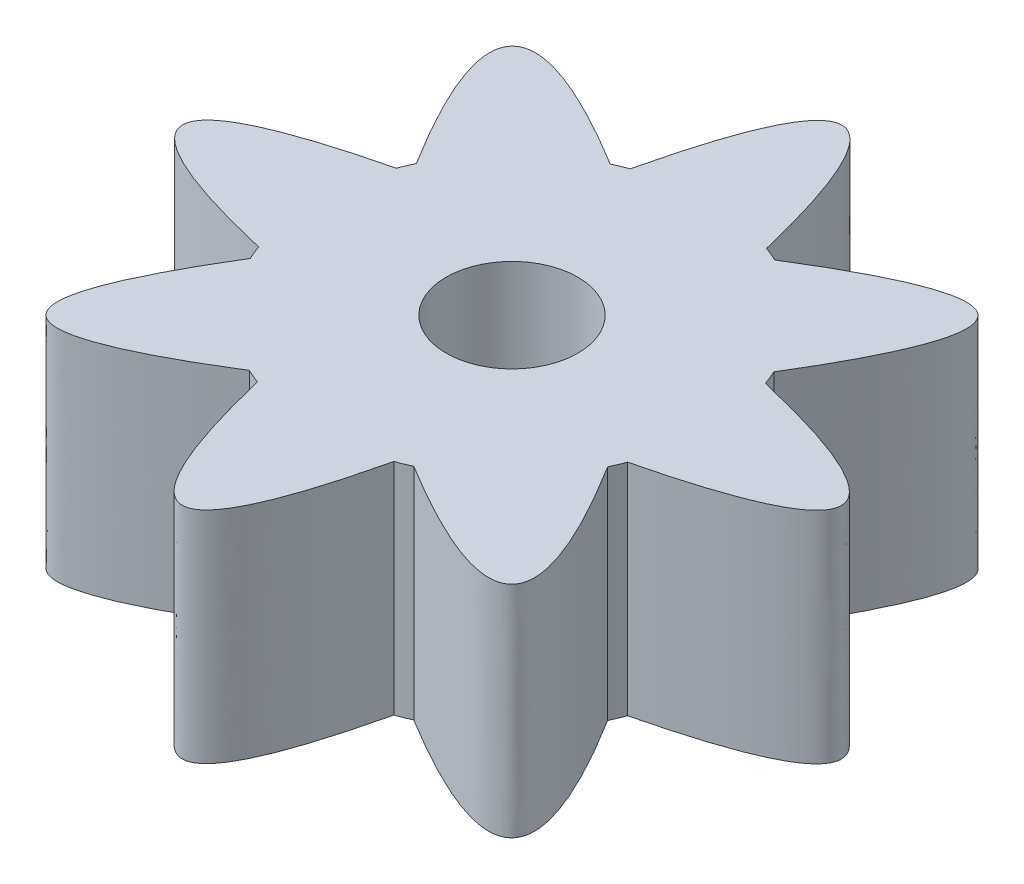
from build123d import *

# Parameters (mm, degrees)
SKETCH3_R           = 4.5
BOSS_EXTRUDE2_DEPTH = 2.5
BOSS_EXTRUDE3_DEPTH = 5
CIRPATTERN1_COUNT   = 8
SKETCH7_R           = 1.5
CUT_EXTRUDE1_DEPTH  = 5


with BuildPart() as part:
    # Sketch3 → Boss-Extrude2 (new body, symmetric)
    with BuildSketch(Plane(origin=(0, 0, 0), x_dir=(1, 0, 0), z_dir=(0, 1, 0))):
        with Locations((-6, -42.5)):
            Circle(SKETCH3_R)
    extrude(amount=BOSS_EXTRUDE2_DEPTH, both=True)

    # Sketch5 → Boss-Extrude3 (add, through all)
    with BuildSketch(Plane.XZ.offset(2.5)):
        with BuildLine():
            Line((-7.58091961, 46.713157152), (-4.460558472, 46.728489066))
            add(Edge.make_bspline(
                [(-7.58091961, 46.713157152), (-5.992864636, 53.279234709), (-4.460558472, 46.728489066)],
                knots=[0, 0, 0, 1, 1, 1], degree=2))
        make_face()
    boss_extrude3 = extrude(amount=-BOSS_EXTRUDE3_DEPTH)

    # CirPattern1: Boss-Extrude3 ×8 about axis
    cirpattern1_axis = Axis((-6, -2.5, 42.5), (0, 1, 0))
    for i in range(1, CIRPATTERN1_COUNT):
        add(boss_extrude3.rotate(cirpattern1_axis, i * 360 / CIRPATTERN1_COUNT))

    # Sketch7 → Cut-Extrude1 (cut)
    with BuildSketch(Plane.XZ.offset(2.5)):
        with Locations((-6, 42.5)):
            Circle(SKETCH7_R)
    extrude(amount=-CUT_EXTRUDE1_DEPTH, mode=Mode.SUBTRACT)


solid = part.part
